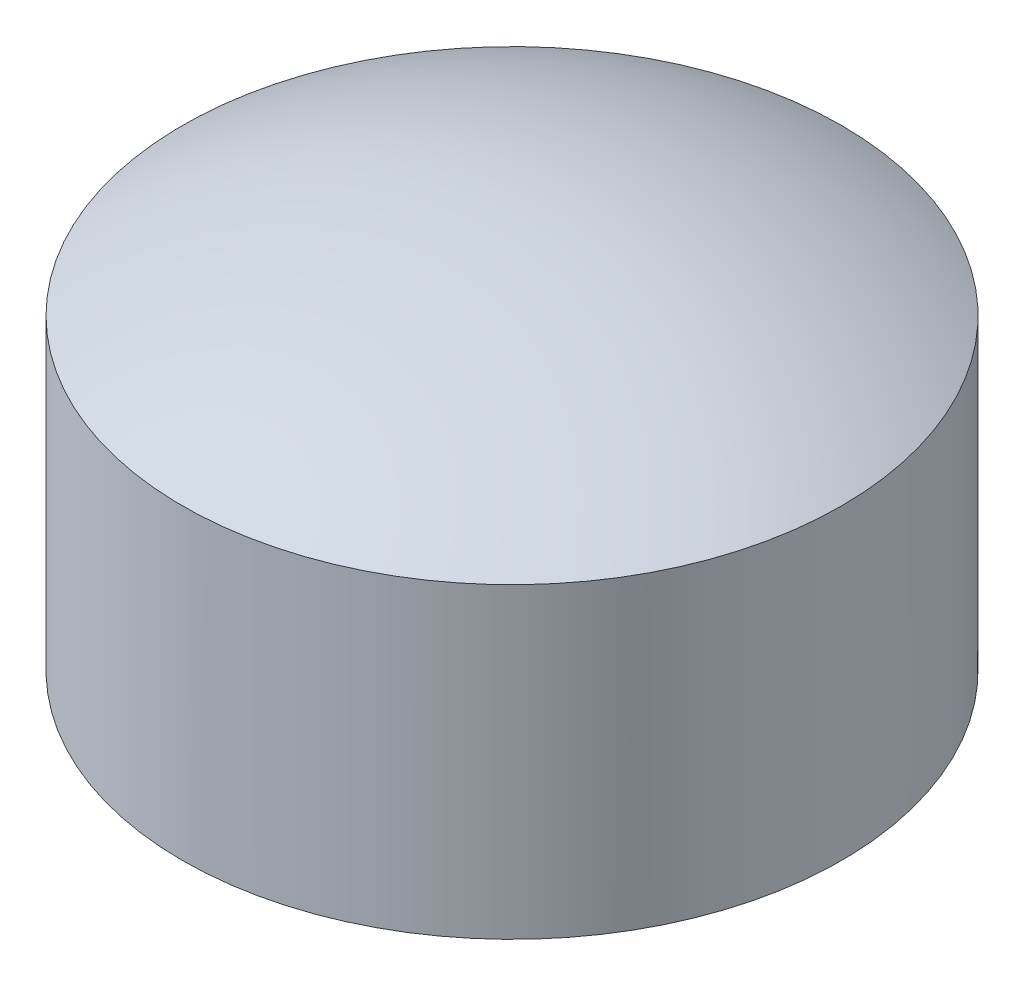
from build123d import *

# Parameters (mm, degrees)
SKETCH2_R           = 5
BOSS_EXTRUDE1_DEPTH = 8
SKETCH4_R           = 23.702642413
SKETCH4_R_2         = 5
CUT_EXTRUDE1_DEPTH  = 28
SKETCH5_R           = 5
CUT_EXTRUDE2_DEPTH  = 18


with BuildPart() as part:
    # Sketch2 → Boss-Extrude1 (new body)
    with BuildSketch(Plane(origin=(0, 0, 0), x_dir=(1, 0, 0), z_dir=(0, 1, 0))):
        Circle(SKETCH2_R)
    extrude(amount=BOSS_EXTRUDE1_DEPTH)

    # Sketch3 one side → Revolve1 (revolve)
    with BuildSketch(Plane.XY):
        with BuildLine():
            ThreePointArc((0, 4), (7.071067812, 6.928932188), (10, 14))
            ThreePointArc((10, 14), (7.071067812, 21.071067812), (0, 24))
            Line((0, 24), (0, 4))
        make_face()
    revolve(axis=Axis((0, 24, 0), (0, -1, 0)))

    # Sketch4 → Cut-Extrude1 (cut)
    with BuildSketch(Plane.XZ):
        Circle(SKETCH4_R)
        Circle(SKETCH4_R_2, mode=Mode.SUBTRACT)
    extrude(amount=-CUT_EXTRUDE1_DEPTH, mode=Mode.SUBTRACT)

    # Sketch5 → Cut-Extrude2 (cut)
    with BuildSketch(Plane.XZ):
        Circle(SKETCH5_R)
    extrude(amount=-CUT_EXTRUDE2_DEPTH, mode=Mode.SUBTRACT)


solid = part.part
